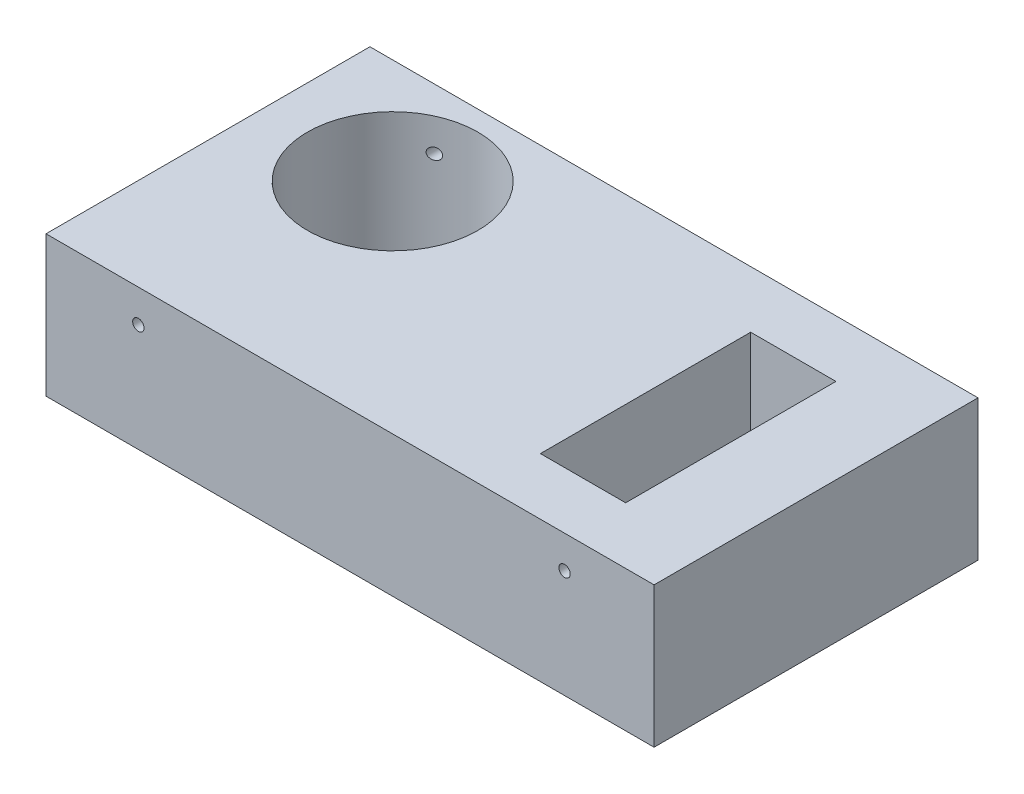
from build123d import *

# Parameters (mm, degrees)
SKETCH1_W           = 214
SKETCH1_H           = 114
BOSS_EXTRUDE1_DEPTH = 49.5
SKETCH2_R           = 2
CUT_EXTRUDE1_DEPTH  = 115
SKETCH4_R           = 30
SKETCH4_W           = 30
SKETCH4_H           = 74
CUT_EXTRUDE2_DEPTH  = 55


with BuildPart() as part:
    # Sketch1 → Boss-Extrude1 (new body)
    with BuildSketch(Plane(origin=(0, 0, 0), x_dir=(1, 0, 0), z_dir=(0, 1, 0))):
        Rectangle(SKETCH1_W, SKETCH1_H)
    extrude(amount=BOSS_EXTRUDE1_DEPTH)

    # Sketch2 → Cut-Extrude1 (cut, through all)
    with BuildSketch(Plane.XY.offset(57)):
        with Locations((-74.5, 38)):
            Circle(SKETCH2_R)
        with Locations((75.5, 38)):
            Circle(SKETCH2_R)
    extrude(amount=-CUT_EXTRUDE1_DEPTH, mode=Mode.SUBTRACT)

    # Sketch4 → Cut-Extrude2 (cut)
    with BuildSketch(Plane.XZ):
        with Locations((-62, -20)):
            Circle(SKETCH4_R)
        with Locations((62, 0)):
            Rectangle(SKETCH4_W, SKETCH4_H)
    extrude(amount=-CUT_EXTRUDE2_DEPTH, mode=Mode.SUBTRACT)


solid = part.part
